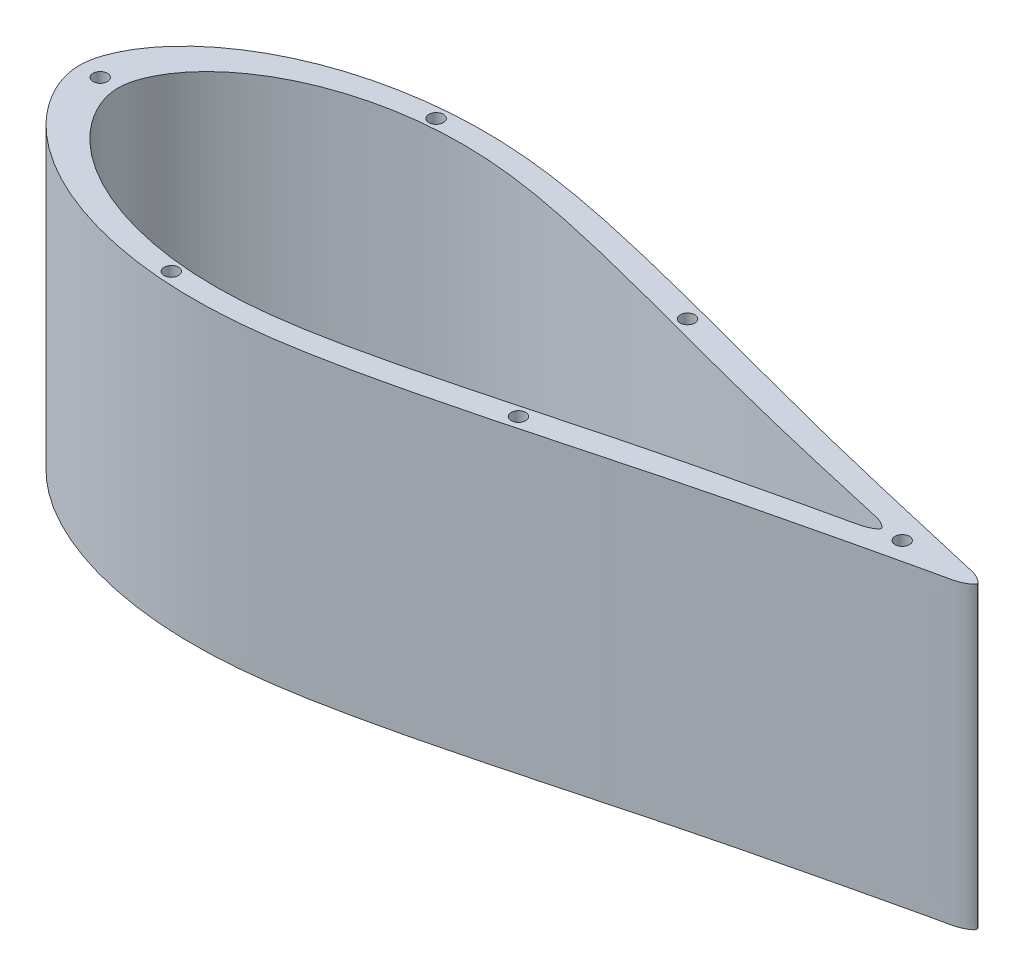
from build123d import *

# Parameters (mm, degrees)
BOSS_EXTRUDE1_DEPTH = 100
CUT_EXTRUDE8_REACH  = 321.935
SKETCH12_R          = 2.415
CUT_EXTRUDE9_DEPTH  = 320.93545114


with BuildPart() as part:
    # Sketch3 → Boss-Extrude1 (new body)
    with BuildSketch(Plane(origin=(0, 0, 0), x_dir=(1, 0, 0), z_dir=(0, 1, 0))):
        with BuildLine():
            add(Edge.make_bspline(
                [(0, 0), (0, -1.869412992), (0.64834316, -5.798703671), (3.031066686, -11.533576223), (6.653304031, -17.267010725), (11.471716912, -22.837096521), (17.430196145, -28.115434217), (24.465941762, -32.99859482), (32.527857891, -37.372315002), (41.538857724, -41.160691823), (51.431441971, -44.265106616), (62.11578082, -46.628168346), (73.525967425, -48.154878004), (85.611384032, -48.728354206), (98.342557923, -48.310477324), (111.725712529, -46.847858839), (125.760588908, -44.412209991), (140.434286751, -41.288720883), (155.634740935, -37.661490146), (171.176973505, -33.699494803), (186.853926113, -29.566356331), (202.431772576, -25.419418935), (217.9956614, -21.266300687), (233.208366579, -17.405000658), (247.68379827, -13.874815175), (260.725101784, -10.789740345), (272.105235179, -8.142980553), (281.711602995, -5.979406788), (289.207502575, -4.168959476), (295.036688315, -3.096938852), (298.170873437, -1.894998614), (300.577567682, 0), (298.170873437, 1.894998614), (295.036688315, 3.096938852), (289.207502575, 4.168959476), (281.711602995, 5.979406788), (272.105235179, 8.142980553), (260.725101784, 10.789740345), (247.68379827, 13.874815175), (233.208366579, 17.405000658), (217.9956614, 21.266300687), (202.431772576, 25.419418935), (186.853926113, 29.566356331), (171.176973505, 33.699494803), (155.634740935, 37.661490146), (140.434286751, 41.288720883), (125.760588908, 44.412209991), (111.725712529, 46.847858839), (98.342557923, 48.310477324), (85.611384032, 48.728354206), (73.525967425, 48.154878004), (62.11578082, 46.628168346), (51.431441971, 44.265106616), (41.538857724, 41.160691823), (32.527857891, 37.372315002), (24.465941762, 32.99859482), (17.430196145, 28.115434217), (11.471716912, 22.837096521), (6.653304031, 17.267010725), (3.031066686, 11.533576223), (0.64834316, 5.798703671), (0, 1.869412992), (0, 0)],
                knots=[0, 0, 0, 0, 0.008569339, 0.018011763, 0.028335072, 0.039554377, 0.051690855, 0.064762326, 0.078762966, 0.093695745, 0.109541044, 0.126268233, 0.143840833, 0.162293053, 0.181714548, 0.202223429, 0.224008172, 0.24704197, 0.271045998, 0.295701517, 0.320629039, 0.345429601, 0.369662175, 0.394534742, 0.417435645, 0.438026555, 0.456003621, 0.471089893, 0.483064812, 0.491749677, 0.497394866, 0.5, 0.502605134, 0.508250323, 0.516935188, 0.528910107, 0.543996379, 0.561973445, 0.582564355, 0.605465258, 0.630337825, 0.654570399, 0.679370961, 0.704298483, 0.728954002, 0.75295803, 0.775991828, 0.797776571, 0.818285452, 0.837706947, 0.856159167, 0.873731767, 0.890458956, 0.906304255, 0.921237034, 0.935237674, 0.948309145, 0.960445623, 0.971664928, 0.981988237, 0.991430661, 1, 1, 1, 1], degree=3))
        make_face()
    extrude(amount=BOSS_EXTRUDE1_DEPTH)

    # Sketch12 → Cut-Extrude8 (cut, up to next)
    with BuildSketch(Plane(origin=(0, 100, 0), x_dir=(1, 0, 0), z_dir=(0, 1, 0)), mode=Mode.PRIVATE) as cut_extrude8_sk1:
        with BuildLine():
            ThreePointArc((272.585, 0), (275, -2.415), (277.415, 0))
            Line((277.415, 0), (272.585, 0))
        make_face()
    cut_extrude8_tool1 = extrude(cut_extrude8_sk1.sketch, amount=-CUT_EXTRUDE8_REACH, mode=Mode.PRIVATE) & part.part
    # Sketch12 → Cut-Extrude8 (cut, up to next)
    with BuildSketch(Plane(origin=(0, 100, 0), x_dir=(1, 0, 0), z_dir=(0, 1, 0)), mode=Mode.PRIVATE) as cut_extrude8_sk2:
        with BuildLine():
            Line((272.585, 0), (277.415, 0))
            ThreePointArc((277.415, 0), (275, 2.415), (272.585, 0))
        make_face()
    cut_extrude8_tool2 = extrude(cut_extrude8_sk2.sketch, amount=-CUT_EXTRUDE8_REACH, mode=Mode.PRIVATE) & part.part
    # Sketch12 → Cut-Extrude8 (cut, up to next)
    with BuildSketch(Plane(origin=(0, 100, 0), x_dir=(1, 0, 0), z_dir=(0, 1, 0)), mode=Mode.PRIVATE) as cut_extrude8_sk3:
        with BuildLine():
            ThreePointArc((272.585, 0), (275, -2.415), (277.415, 0))
            Line((277.415, 0), (272.585, 0))
        make_face()
    cut_extrude8_tool3 = extrude(cut_extrude8_sk3.sketch, amount=-CUT_EXTRUDE8_REACH, mode=Mode.PRIVATE) & part.part
    # Sketch12 → Cut-Extrude8 (cut, up to next)
    with BuildSketch(Plane(origin=(0, 100, 0), x_dir=(1, 0, 0), z_dir=(0, 1, 0)), mode=Mode.PRIVATE) as cut_extrude8_sk4:
        with BuildLine():
            Line((272.585, 0), (277.415, 0))
            ThreePointArc((277.415, 0), (275, 2.415), (272.585, 0))
        make_face()
    cut_extrude8_tool4 = extrude(cut_extrude8_sk4.sketch, amount=-CUT_EXTRUDE8_REACH, mode=Mode.PRIVATE) & part.part
    # Sketch12 → Cut-Extrude8 (cut, up to next)
    with BuildSketch(Plane(origin=(0, 100, 0), x_dir=(1, 0, 0), z_dir=(0, 1, 0)), mode=Mode.PRIVATE) as cut_extrude8_sk5:
        with Locations(Location((75, 44.25, 0), (0, 0, 270))):
            Circle(SKETCH12_R)
    cut_extrude8_tool5 = extrude(cut_extrude8_sk5.sketch, amount=-CUT_EXTRUDE8_REACH, mode=Mode.PRIVATE) & part.part
    # Sketch12 → Cut-Extrude8 (cut, up to next)
    with BuildSketch(Plane(origin=(0, 100, 0), x_dir=(1, 0, 0), z_dir=(0, 1, 0)), mode=Mode.PRIVATE) as cut_extrude8_sk6:
        with BuildLine():
            ThreePointArc((4.585, 0), (7, -2.415), (9.415, 0))
            Line((9.415, 0), (4.585, 0))
        make_face()
    cut_extrude8_tool6 = extrude(cut_extrude8_sk6.sketch, amount=-CUT_EXTRUDE8_REACH, mode=Mode.PRIVATE) & part.part
    # Sketch12 → Cut-Extrude8 (cut, up to next)
    with BuildSketch(Plane(origin=(0, 100, 0), x_dir=(1, 0, 0), z_dir=(0, 1, 0)), mode=Mode.PRIVATE) as cut_extrude8_sk7:
        with BuildLine():
            Line((4.585, 0), (9.415, 0))
            ThreePointArc((9.415, 0), (7, 2.415), (4.585, 0))
        make_face()
    cut_extrude8_tool7 = extrude(cut_extrude8_sk7.sketch, amount=-CUT_EXTRUDE8_REACH, mode=Mode.PRIVATE) & part.part
    # Sketch12 → Cut-Extrude8 (cut, up to next)
    with BuildSketch(Plane(origin=(0, 100, 0), x_dir=(1, 0, 0), z_dir=(0, 1, 0)), mode=Mode.PRIVATE) as cut_extrude8_sk8:
        with BuildLine():
            ThreePointArc((4.585, 0), (7, -2.415), (9.415, 0))
            Line((9.415, 0), (4.585, 0))
        make_face()
    cut_extrude8_tool8 = extrude(cut_extrude8_sk8.sketch, amount=-CUT_EXTRUDE8_REACH, mode=Mode.PRIVATE) & part.part
    # Sketch12 → Cut-Extrude8 (cut, up to next)
    with BuildSketch(Plane(origin=(0, 100, 0), x_dir=(1, 0, 0), z_dir=(0, 1, 0)), mode=Mode.PRIVATE) as cut_extrude8_sk9:
        with BuildLine():
            Line((4.585, 0), (9.415, 0))
            ThreePointArc((9.415, 0), (7, 2.415), (4.585, 0))
        make_face()
    cut_extrude8_tool9 = extrude(cut_extrude8_sk9.sketch, amount=-CUT_EXTRUDE8_REACH, mode=Mode.PRIVATE) & part.part
    # Sketch12 → Cut-Extrude8 (cut, up to next)
    with BuildSketch(Plane(origin=(0, 100, 0), x_dir=(1, 0, 0), z_dir=(0, 1, 0)), mode=Mode.PRIVATE) as cut_extrude8_sk10:
        with Locations(Location((75, -44.25, 0), (0, 0, 270))):
            Circle(SKETCH12_R)
    cut_extrude8_tool10 = extrude(cut_extrude8_sk10.sketch, amount=-CUT_EXTRUDE8_REACH, mode=Mode.PRIVATE) & part.part
    # Sketch12 → Cut-Extrude8 (cut, up to next)
    with BuildSketch(Plane(origin=(0, 100, 0), x_dir=(1, 0, 0), z_dir=(0, 1, 0)), mode=Mode.PRIVATE) as cut_extrude8_sk11:
        with Locations(Location((175, -28.25, 0), (0, 0, 270))):
            Circle(SKETCH12_R)
    cut_extrude8_tool11 = extrude(cut_extrude8_sk11.sketch, amount=-CUT_EXTRUDE8_REACH, mode=Mode.PRIVATE) & part.part
    # Sketch12 → Cut-Extrude8 (cut, up to next)
    with BuildSketch(Plane(origin=(0, 100, 0), x_dir=(1, 0, 0), z_dir=(0, 1, 0)), mode=Mode.PRIVATE) as cut_extrude8_sk12:
        with Locations(Location((175, 28.25, 0), (0, 0, 90))):
            Circle(SKETCH12_R)
    cut_extrude8_tool12 = extrude(cut_extrude8_sk12.sketch, amount=-CUT_EXTRUDE8_REACH, mode=Mode.PRIVATE) & part.part
    add(cut_extrude8_tool1.solids().sort_by_distance((275, 100, 1.024958))[0], mode=Mode.SUBTRACT)
    add(cut_extrude8_tool2.solids().sort_by_distance((275, 100, -1.024958))[0], mode=Mode.SUBTRACT)
    add(cut_extrude8_tool3.solids().sort_by_distance((275, 100, 1.024958))[0], mode=Mode.SUBTRACT)
    add(cut_extrude8_tool4.solids().sort_by_distance((275, 100, -1.024958))[0], mode=Mode.SUBTRACT)
    add(cut_extrude8_tool5.solids().sort_by_distance((75, 100, -44.25))[0], mode=Mode.SUBTRACT)
    add(cut_extrude8_tool6.solids().sort_by_distance((7, 100, 1.024958))[0], mode=Mode.SUBTRACT)
    add(cut_extrude8_tool7.solids().sort_by_distance((7, 100, -1.024958))[0], mode=Mode.SUBTRACT)
    add(cut_extrude8_tool8.solids().sort_by_distance((7, 100, 1.024958))[0], mode=Mode.SUBTRACT)
    add(cut_extrude8_tool9.solids().sort_by_distance((7, 100, -1.024958))[0], mode=Mode.SUBTRACT)
    add(cut_extrude8_tool10.solids().sort_by_distance((75, 100, 44.25))[0], mode=Mode.SUBTRACT)
    add(cut_extrude8_tool11.solids().sort_by_distance((175, 100, 28.25))[0], mode=Mode.SUBTRACT)
    add(cut_extrude8_tool12.solids().sort_by_distance((175, 100, -28.25))[0], mode=Mode.SUBTRACT)

    # Sketch13 → Cut-Extrude9 (cut, through all)
    with BuildSketch(Plane(origin=(0, 100, 0), x_dir=(1, 0, 0), z_dir=(0, 1, 0))):
        with BuildLine():
            add(Edge.make_bspline(
                [(268, 0), (268.001856039, -0.029239319), (268.000355247, -0.087981363), (267.985880763, -0.160369385), (267.963245559, -0.231119027), (267.93921531, -0.286160505), (267.903262714, -0.352574716), (267.862094545, -0.416510663), (267.788046248, -0.5133118), (267.705318112, -0.602560444), (267.617538135, -0.68629492), (267.549695797, -0.746717393), (267.480155196, -0.805058161), (267.338227236, -0.918132219), (267.117296362, -1.076967164), (266.865143575, -1.242906892), (266.659623285, -1.369454403), (266.451700145, -1.491876939), (266.187443844, -1.637158971), (265.863921164, -1.799093809), (265.534520185, -1.948591444), (265.199801579, -2.085701751), (264.860488879, -2.211060268), (264.403008326, -2.364613604), (263.823806533, -2.535214559), (263.122912229, -2.717739156), (262.418222727, -2.884279003), (261.474966952, -3.090807483), (259.818047166, -3.424527169), (257.456500274, -3.923037707), (254.635964826, -4.580157785), (251.815916672, -5.239568033), (248.99439581, -5.892700907), (246.171439171, -6.539592487), (243.348549652, -7.186787076), (240.996536661, -7.727831698), (239.11541125, -8.162773426), (236.29421349, -8.817309667), (233.00423706, -9.587073118), (228.30669123, -10.697065808), (223.611615327, -11.817525616), (217.982046364, -13.180812394), (210.482839189, -15.026465793), (201.123197574, -17.391059123), (189.91973165, -20.337644591), (180.592782412, -22.828626782), (173.1295132, -24.814930541), (167.530399853, -26.298408631), (161.928392865, -27.770975469), (156.322217932, -29.227628214), (150.710337653, -30.662139527), (143.217806211, -32.534764672), (135.706975658, -34.33390377), (128.169402634, -36.017639171), (122.500074926, -37.206127525), (116.811624671, -38.304780419), (109.198768266, -39.609998286), (99.621118622, -40.850051846), (88.041851948, -41.472058807), (76.452792056, -41.087324662), (66.868686587, -39.830861772), (59.310636854, -38.232283411), (53.713786165, -36.728022572), (48.212152388, -34.902853508), (41.049799279, -32.01104126), (34.201147675, -28.389596996), (27.887363161, -23.926675546), (24.2309751, -20.764128582), (21.535440676, -17.996252757), (19.648148706, -15.797868092), (17.916209787, -13.474555331), (16.366808436, -11.027032173), (15.023622901, -8.455898853), (13.945542363, -5.762927499), (13.204380872, -2.956931725), (12.963272671, -0.546790069), (13.053109688, 1.380665244), (13.315278598, 3.293056107), (13.924391451, 5.635470357), (14.998339036, 8.331635602), (16.33249369, 10.905747514), (17.878730654, 13.356352362), (19.32036008, 15.294889845), (20.550485099, 16.783157809), (21.509293482, 17.868337505), (22.501630908, 18.922890279), (24.548517813, 20.971535201), (27.106413017, 23.188021248), (29.814499039, 25.209006962), (31.40061839, 26.309590695), (32.709032196, 27.174855), (34.140500896, 28.072112031), (35.594882503, 28.931729371), (38.436658622, 30.525594553), (41.688520706, 32.125905338), (45.465527137, 33.729879845), (49.067772638, 35.121571151), (53.650264544, 36.646222375), (59.246396331, 38.153243682), (66.804706599, 39.75545326), (74.471206959, 40.76706721), (82.182255046, 41.213983688), (87.009717018, 41.271123206), (90.388014534, 41.201484094), (92.799937126, 41.113798662), (94.969298883, 41.001302883), (97.858688221, 40.800979303), (100.26298199, 40.587675002), (102.903490144, 40.311166455), (105.30038832, 40.027981052), (108.17035509, 39.640370629), (111.988878171, 39.065941554), (115.795655631, 38.414078604), (119.591504548, 37.702943397), (122.433279246, 37.143774071), (125.27033518, 36.561505106), (128.103023294, 35.958444004), (130.931689283, 35.336773665), (134.698310801, 34.485638355), (139.398172867, 33.384992559), (145.026850969, 32.018196574), (150.646194968, 30.613346399), (156.2580821, 29.178744823), (163.733121764, 27.237041746), (171.199869602, 25.263866022), (178.663023897, 23.277086236), (184.259744959, 21.784562357), (189.857200214, 20.294844666), (195.457568999, 18.816371392), (202.93140426, 16.870842191), (212.29100661, 14.506077528), (221.66992611, 12.218617115), (229.181922805, 10.425367078), (234.819592512, 9.096021621), (239.520812515, 8.001845203), (242.813852338, 7.245403789), (244.695937653, 6.81465989), (246.107538034, 6.491755082), (247.283811571, 6.22240099), (248.45996139, 5.952503645), (249.400736995, 5.735953058), (250.57643052, 5.464055273), (251.751759418, 5.190561123), (253.16161572, 4.860006012), (255.041592843, 4.420030946), (256.922674926, 3.984775573), (258.808529434, 3.571263479), (260.22691478, 3.279697018), (261.645949341, 2.989746839), (262.825082314, 2.729200825), (263.761165057, 2.489703397), (264.456490765, 2.286529525), (265.140876635, 2.050907752), (265.696255334, 1.8165517), (266.128837732, 1.603346211), (266.446974109, 1.43100259), (266.758351417, 1.246365771), (267.011762568, 1.082364947), (267.210711364, 0.945284168), (267.357303707, 0.838625419), (267.499808207, 0.726290814), (267.636782848, 0.606554654), (267.744261618, 0.498610011), (267.823110906, 0.405595919), (267.877006116, 0.332051829), (267.924073311, 0.254348264), (267.962223044, 0.172601652), (267.984698319, 0.10163968), (267.995912723, 0.043793127), (267.99907198, 0.01461966), (268, 0)],
                knots=[0, 0, 0, 0, 0.00016276, 0.000325521, 0.000406901, 0.000569661, 0.000651042, 0.000813802, 0.000976562, 0.001302083, 0.001464844, 0.001627604, 0.001790365, 0.001953125, 0.002604167, 0.003255208, 0.003580729, 0.00390625, 0.004557292, 0.005208333, 0.005859375, 0.006510417, 0.007161458, 0.0078125, 0.009114583, 0.010416667, 0.01171875, 0.013020833, 0.015625, 0.020833333, 0.026041667, 0.03125, 0.036458333, 0.041666667, 0.046875, 0.052083333, 0.0546875, 0.057291667, 0.067708333, 0.072916667, 0.083333333, 0.09375, 0.104166667, 0.125, 0.145833333, 0.166666667, 0.177083333, 0.1875, 0.197916667, 0.208333333, 0.21875, 0.229166667, 0.25, 0.260416667, 0.270833333, 0.28125, 0.291666667, 0.3125, 0.333333333, 0.354166667, 0.375, 0.385416667, 0.395833333, 0.40625, 0.416666667, 0.4375, 0.447916667, 0.458333333, 0.463541667, 0.46875, 0.473958333, 0.479166667, 0.484375, 0.489583333, 0.494791667, 0.5, 0.502604167, 0.505208333, 0.510416667, 0.515625, 0.520833333, 0.526041667, 0.53125, 0.533854167, 0.536458333, 0.5390625, 0.541666667, 0.552083333, 0.557291667, 0.559895833, 0.5625, 0.565755208, 0.569010417, 0.571614583, 0.583333333, 0.588541667, 0.59375, 0.604166667, 0.614583333, 0.625, 0.645833333, 0.65625, 0.666666667, 0.671875, 0.674479167, 0.6796875, 0.68359375, 0.690104167, 0.692708333, 0.697916667, 0.703125, 0.708333333, 0.71875, 0.723958333, 0.729166667, 0.734375, 0.739583333, 0.744791667, 0.75, 0.760416667, 0.770833333, 0.78125, 0.791666667, 0.802083333, 0.822916667, 0.833333333, 0.84375, 0.854166667, 0.864583333, 0.875, 0.895833333, 0.916666667, 0.927083333, 0.9375, 0.947916667, 0.953125, 0.955729167, 0.958333333, 0.9609375, 0.962239583, 0.96484375, 0.966145833, 0.96875, 0.971354167, 0.973958333, 0.979166667, 0.981770833, 0.984375, 0.986979167, 0.989583333, 0.990885417, 0.9921875, 0.993489583, 0.994791667, 0.995442708, 0.99609375, 0.996744792, 0.997395833, 0.997721354, 0.998046875, 0.998372396, 0.998697917, 0.999023438, 0.999186198, 0.999348958, 0.999511719, 0.999674479, 0.99983724, 0.99991862, 1, 1, 1, 1], degree=3))
        make_face()
    extrude(amount=-CUT_EXTRUDE9_DEPTH, mode=Mode.SUBTRACT)


solid = part.part
